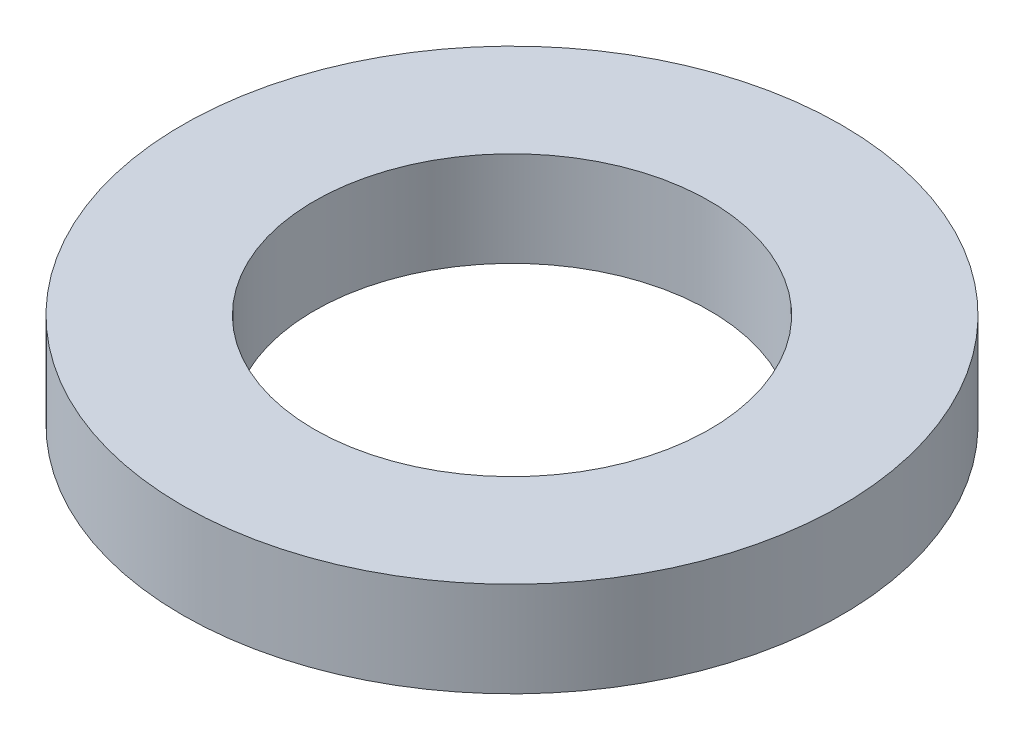
from build123d import *

# Parameters (mm, degrees)
SKETCH1_R           = 6.25
SKETCH1_R_2         = 3.75
BOSS_EXTRUDE1_DEPTH = 0.9


with BuildPart() as part:
    # Sketch1 → Boss-Extrude1 (new body, symmetric)
    with BuildSketch(Plane(origin=(0, 0, 0), x_dir=(1, 0, 0), z_dir=(0, 1, 0))):
        Circle(SKETCH1_R)
        Circle(SKETCH1_R_2, mode=Mode.SUBTRACT)
    extrude(amount=BOSS_EXTRUDE1_DEPTH, both=True)


solid = part.part
